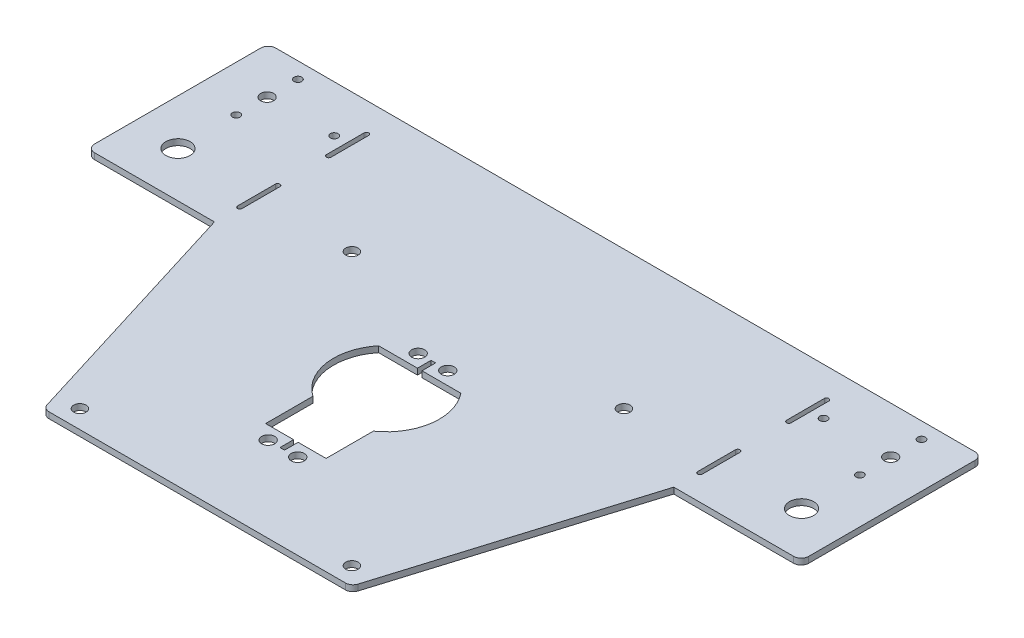
from build123d import *

# Parameters (mm, degrees)
SKETCH26_R          = 2.05
SKETCH26_R_2        = 2.15
SKETCH26_R_3        = 4
SKETCH26_R_4        = 1.27
SKETCH26_R_5        = 2.141312715
BOSS_EXTRUDE4_DEPTH = 2


with BuildPart() as part:
    # Sketch26 → Boss-Extrude4 (new body)
    with BuildSketch(Plane(origin=(0, 0, 0), x_dir=(1, 0, 0), z_dir=(0, 1, 0))):
        with BuildLine():
            Line((75.767236042, 90.766820858), (50.767236042, 90.766820858))
            Line((50.767236042, 90.766820858), (-51.032763958, 90.766820858))
            Line((-51.032763958, 90.766820858), (-76.278800323, 90.766820858))
            Line((-76.278800323, 90.766820858), (-115.954777141, 90.766820858))
            ThreePointArc((-115.954777141, 90.766820858), (-117.722544094, 90.034587811), (-118.454777141, 88.266820858))
            Line((-118.454777141, 88.266820858), (-118.454777141, 33.266820858))
            ThreePointArc((-118.454777141, 33.266820858), (-117.722544094, 31.499053905), (-115.954777141, 30.766820858))
            Line((-115.954777141, 30.766820858), (-76.278800323, 30.766820858))
            Line((-76.278800323, 30.766820858), (-51.571443107, -49.270587217))
            ThreePointArc((-51.571443107, -49.270587217), (-50.667003064, -50.544835199), (-49.182671596, -51.033179142))
            Line((-49.182671596, -51.033179142), (48.917143681, -51.033179142))
            ThreePointArc((48.917143681, -51.033179142), (50.404299167, -50.542748389), (51.307977226, -49.26387399))
            Line((51.307977226, -49.26387399), (75.767236042, 30.766820858))
            Line((75.767236042, 30.766820858), (115.443212861, 30.766820858))
            ThreePointArc((115.443212861, 30.766820858), (117.210979814, 31.499053905), (117.943212861, 33.266820858))
            Line((117.943212861, 33.266820858), (117.943212861, 88.266820858))
            ThreePointArc((117.943212861, 88.266820858), (117.210979814, 90.034587811), (115.443212861, 90.766820858))
            Line((115.443212861, 90.766820858), (75.767236042, 90.766820858))
        make_face()
        with Locations((-45.02, -45.02)):
            Circle(SKETCH26_R, mode=Mode.SUBTRACT)
        with Locations((-4.845188419, -22.879546923)):
            Circle(SKETCH26_R_2, mode=Mode.SUBTRACT)
        with Locations((45.02, -45.02)):
            Circle(SKETCH26_R, mode=Mode.SUBTRACT)
        with Locations((4.954811581, -22.879546923)):
            Circle(SKETCH26_R_2, mode=Mode.SUBTRACT)
        with BuildLine():
            Line((-13.610657589, 22.45), (-0.75, 22.45))
            Line((-0.75, 22.45), (-0.75, 26.95))
            Line((-0.75, 26.95), (0.75, 26.95))
            Line((0.75, 26.95), (0.75, 22.45))
            Line((0.75, 22.45), (10, 22.45))
            Line((10, 22.45), (13.610657589, 22.45))
            ThreePointArc((13.610657589, 22.45), (17.325300122, 8.983428358), (10, -2.911406616))
            Line((10, -2.911406616), (10, -18.55))
            Line((10, -18.55), (0.75, -18.55))
            Line((0.75, -18.55), (0.75, -23.05))
            Line((0.75, -23.05), (-0.75, -23.05))
            Line((-0.75, -23.05), (-0.75, -18.55))
            Line((-0.75, -18.55), (-10, -18.55))
            Line((-10, -18.55), (-10, -2.911406616))
            ThreePointArc((-10, -2.911406616), (-17.325300122, 8.983428358), (-13.610657589, 22.45))
        make_face(mode=Mode.SUBTRACT)
        with Locations((-103.332763958, 45.766820858)):
            Circle(SKETCH26_R_3, mode=Mode.SUBTRACT)
        with BuildLine():
            ThreePointArc((-75.528800323, 39.191107079), (-76.278800323, 38.441107079), (-77.028800323, 39.191107079))
            Line((-77.028800323, 39.191107079), (-77.028800323, 51.691107079))
            ThreePointArc((-77.028800323, 51.691107079), (-76.278800323, 52.441107079), (-75.528800323, 51.691107079))
            Line((-75.528800323, 51.691107079), (-75.528800323, 39.191107079))
        make_face(mode=Mode.SUBTRACT)
        with Locations((-4.845188419, 26.779546923)):
            Circle(SKETCH26_R_2, mode=Mode.SUBTRACT)
        with Locations((-45.02, 45.02)):
            Circle(SKETCH26_R, mode=Mode.SUBTRACT)
        with Locations((-103.332763958, 65.066820858)):
            Circle(SKETCH26_R_4, mode=Mode.SUBTRACT)
        with Locations((-103.332763958, 75.266820858)):
            Circle(SKETCH26_R_5, mode=Mode.SUBTRACT)
        with Locations((-103.332763958, 85.466820858)):
            Circle(SKETCH26_R_4, mode=Mode.SUBTRACT)
        with BuildLine():
            ThreePointArc((-77.028800323, 81.095149015), (-76.278800323, 81.845149015), (-75.528800323, 81.095149015))
            Line((-75.528800323, 81.095149015), (-75.528800323, 68.595149015))
            ThreePointArc((-75.528800323, 68.595149015), (-76.278800323, 67.845149015), (-77.028800323, 68.595149015))
            Line((-77.028800323, 68.595149015), (-77.028800323, 81.095149015))
        make_face(mode=Mode.SUBTRACT)
        with Locations((-81.132763958, 75.266820858)):
            Circle(SKETCH26_R_4, mode=Mode.SUBTRACT)
        with Locations((4.954811581, 26.779546923)):
            Circle(SKETCH26_R_2, mode=Mode.SUBTRACT)
        with Locations((45.02, 45.02)):
            Circle(SKETCH26_R, mode=Mode.SUBTRACT)
        with BuildLine():
            Line((76.763272408, 51.691107079), (76.763272408, 39.191107079))
            ThreePointArc((76.763272408, 39.191107079), (76.013272408, 38.441107079), (75.263272408, 39.191107079))
            Line((75.263272408, 39.191107079), (75.263272408, 51.691107079))
            ThreePointArc((75.263272408, 51.691107079), (76.013272408, 52.441107079), (76.763272408, 51.691107079))
        make_face(mode=Mode.SUBTRACT)
        with Locations((103.067236042, 45.766820858)):
            Circle(SKETCH26_R_3, mode=Mode.SUBTRACT)
        with Locations((103.067236042, 65.066820858)):
            Circle(SKETCH26_R_4, mode=Mode.SUBTRACT)
        with BuildLine():
            Line((75.263272408, 68.595149015), (75.263272408, 81.095149015))
            ThreePointArc((75.263272408, 81.095149015), (76.013272408, 81.845149015), (76.763272408, 81.095149015))
            Line((76.763272408, 81.095149015), (76.763272408, 68.595149015))
            ThreePointArc((76.763272408, 68.595149015), (76.013272408, 67.845149015), (75.263272408, 68.595149015))
        make_face(mode=Mode.SUBTRACT)
        with Locations((80.867236042, 75.266820858)):
            Circle(SKETCH26_R_4, mode=Mode.SUBTRACT)
        with Locations((103.067236042, 75.266820858)):
            Circle(SKETCH26_R_5, mode=Mode.SUBTRACT)
        with Locations((103.067236042, 85.466820858)):
            Circle(SKETCH26_R_4, mode=Mode.SUBTRACT)
    extrude(amount=BOSS_EXTRUDE4_DEPTH)


solid = part.part
